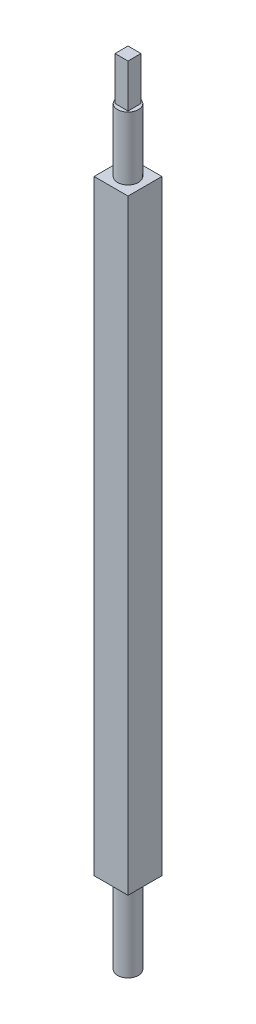
from build123d import *

# Parameters (mm, degrees)
SKETCH1_W           = 11.938
SKETCH1_H           = 11.938
BOSS_EXTRUDE1_DEPTH = 213.106
SKETCH2_R           = 3.68046
BOSS_EXTRUDE2_DEPTH = 22.225
SKETCH3_R           = 3.68046
BOSS_EXTRUDE3_DEPTH = 28.575
SKETCH4_W           = 4.572
SKETCH4_H           = 4.572
BOSS_EXTRUDE4_DEPTH = 15.24


with BuildPart() as part:
    # Sketch1 → Boss-Extrude1 (new body)
    with BuildSketch(Plane(origin=(0, 0, 0), x_dir=(1, 0, 0), z_dir=(0, 1, 0))):
        Rectangle(SKETCH1_W, SKETCH1_H)
    extrude(amount=BOSS_EXTRUDE1_DEPTH)

    # Sketch2 → Boss-Extrude2 (add)
    with BuildSketch(Plane(origin=(0, 213.106, 0), x_dir=(1, 0, 0), z_dir=(0, 1, 0))):
        Circle(SKETCH2_R)
    extrude(amount=BOSS_EXTRUDE2_DEPTH)

    # Sketch3 → Boss-Extrude3 (add)
    with BuildSketch(Plane(origin=(0, 0, 0), x_dir=(-1, 0, 0), z_dir=(0, -1, 0))):
        Circle(SKETCH3_R)
    extrude(amount=BOSS_EXTRUDE3_DEPTH)

    # Sketch4 → Boss-Extrude4 (add)
    with BuildSketch(Plane(origin=(0, 235.331, 0), x_dir=(1, 0, 0), z_dir=(0, 1, 0))):
        Rectangle(SKETCH4_W, SKETCH4_H)
    extrude(amount=BOSS_EXTRUDE4_DEPTH)


solid = part.part
